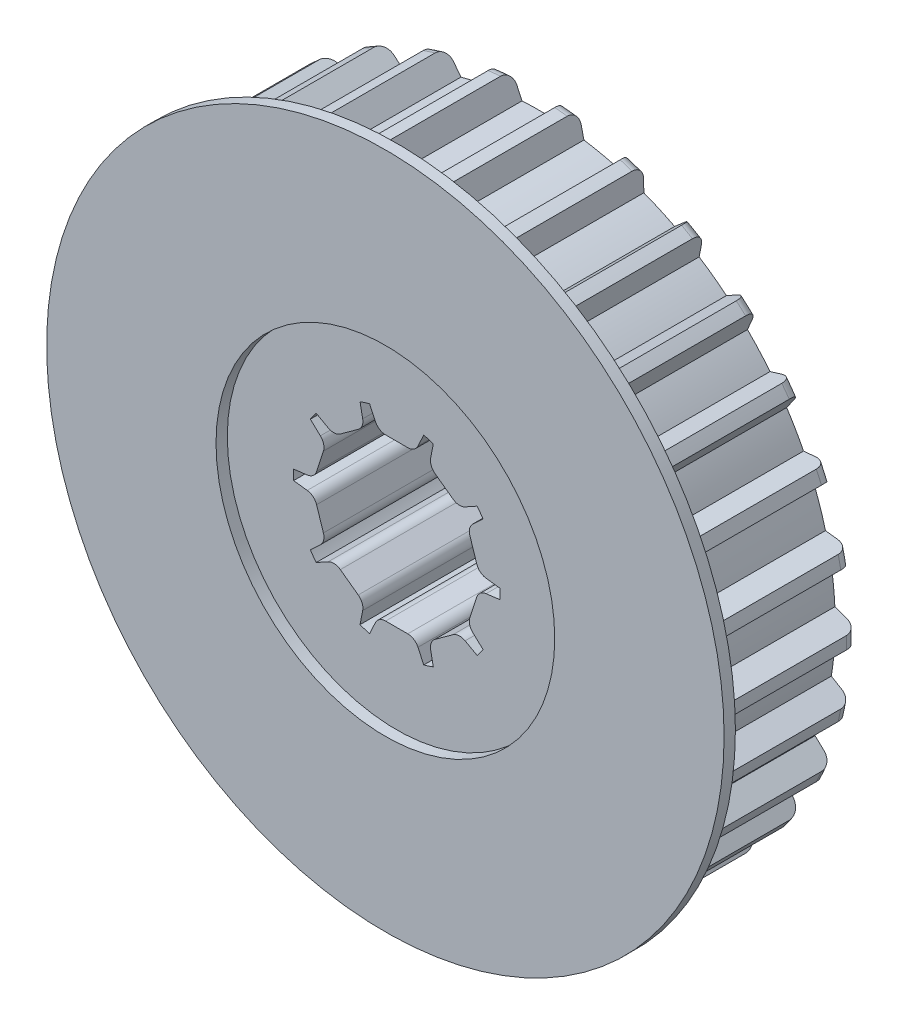
from build123d import *

# Parameters (mm, degrees)
SCHNITT_LINEAR_AUSTRAGEN1_DEPTH = 8.1
KREISMUSTER1_COUNT              = 30
AUFSATZ_LINEAR_AUSTRAGEN1_DEPTH = 7.1
VERRUNDUNG1_R                   = 0.5
KREISMUSTER2_COUNT              = 10
VERRUNDUNG1_OF_KREISMUSTER2_R   = 0.5
VERRUNDUNG2_R                   = 0.5


with BuildPart() as part:
    # Skizze1 → Rotation1 (revolve)
    with BuildSketch(Plane(origin=(0, 0, 0), x_dir=(0, 0, -1), z_dir=(1, 0, 0))):
        with BuildLine():
            Line((0, 4.57), (0, 14.12))
            Line((0, 14.12), (5.8, 14.12))
            ThreePointArc((5.8, 14.12), (6.153553391, 13.973553391), (6.3, 13.62))
            Line((6.3, 13.62), (6.3, 6.1))
            Line((6.3, 6.1), (7.1, 6.1))
            Line((7.1, 6.1), (7.1, 4.57))
            Line((7.1, 4.57), (0, 4.57))
        make_face()
    revolve(axis=Axis((0, 0, 33.276923077), (0, 0, -1)))

    # Skizze2 → Schnitt-Linear austragen1 (cut, through all)
    with BuildSketch(Plane.XY):
        with BuildLine():
            Line((0.747573546, 13.09868443), (1.2, 14.068916092))
            ThreePointArc((1.2, 14.068916092), (0, 14.12), (-1.2, 14.068916092))
            Line((-1.2, 14.068916092), (-0.747573546, 13.09868443))
            ThreePointArc((-0.747573546, 13.09868443), (0, 13.12), (0.747573546, 13.09868443))
        make_face()
    schnitt_linear_austragen1 = extrude(amount=-SCHNITT_LINEAR_AUSTRAGEN1_DEPTH, mode=Mode.SUBTRACT)

    # Kreismuster1: Schnitt-Linear austragen1 ×30 about axis
    kreismuster1_axis = Axis((0, 0, 0), (0, 0, 1))
    for i in range(1, KREISMUSTER1_COUNT):
        add(schnitt_linear_austragen1.rotate(kreismuster1_axis, i * 360 / KREISMUSTER1_COUNT), mode=Mode.SUBTRACT)

    # Skizze3 → Aufsatz-Linear austragen1 (add)
    with BuildSketch(Plane.XY):
        with BuildLine():
            Line((0.808470756, 3.57), (1.2, 4.409637173))
            ThreePointArc((1.2, 4.409637173), (0, 4.57), (-1.2, 4.409637173))
            Line((-1.2, 4.409637173), (-0.808470756, 3.57))
            Line((-0.808470756, 3.57), (0.808470756, 3.57))
        make_face()
    aufsatz_linear_austragen1 = extrude(amount=-AUFSATZ_LINEAR_AUSTRAGEN1_DEPTH)

    # Verrundung1
    verrundung1_edges = [part.edges().sort_by_distance(p)[0] for p in [
        (0.808470756, 3.57, -3.55),
        (-0.808470756, 3.57, -3.55),
    ]]
    fillet(verrundung1_edges, radius=VERRUNDUNG1_R)

    # Kreismuster2: Aufsatz-Linear austragen1 ×10 about axis
    kreismuster2_axis = Axis((0, 0, 0), (0, 0, 1))
    for i in range(1, KREISMUSTER2_COUNT):
        add(aufsatz_linear_austragen1.rotate(kreismuster2_axis, i * 360 / KREISMUSTER2_COUNT))

    # Verrundung1 of Kreismuster2
    verrundung1_of_kreismuster2_edges = [part.edges().sort_by_distance(p)[0] for p in [
        (-1.44432677, 3.363397857, -3.55),
        (-2.752459932, 2.412983483, -3.55),
        (-3.14544056, 1.872092051, -3.55),
        (-3.645102966, 0.334289289, -3.55),
        (-3.645102966, -0.334289289, -3.55),
        (-3.14544056, -1.872092051, -3.55),
        (-2.752459932, -2.412983483, -3.55),
        (-1.44432677, -3.363397857, -3.55),
        (-0.808470756, -3.57, -3.55),
        (0.808470756, -3.57, -3.55),
        (1.44432677, -3.363397857, -3.55),
        (2.752459932, -2.412983483, -3.55),
        (3.14544056, -1.872092051, -3.55),
        (3.645102966, -0.334289289, -3.55),
        (3.645102966, 0.334289289, -3.55),
        (3.14544056, 1.872092051, -3.55),
        (2.752459932, 2.412983483, -3.55),
        (1.44432677, 3.363397857, -3.55),
    ]]
    fillet(verrundung1_of_kreismuster2_edges, radius=VERRUNDUNG1_OF_KREISMUSTER2_R)

    # Skizze4 → Rotation2 (revolve)
    with BuildSketch(Plane(origin=(0, 0, 0), x_dir=(0, 0, -1), z_dir=(1, 0, 0))):
        with BuildLine():
            Line((0, 7.5), (-0.5, 7.5))
            Line((-0.5, 7.5), (-0.5, 15))
            Line((-0.5, 15), (0, 15))
            Line((0, 15), (0, 14.25))
            Line((0, 14.25), (0.653553391, 13.596446609))
            ThreePointArc((0.653553391, 13.596446609), (0.761939766, 13.434234935), (0.8, 13.242893219))
            Line((0.8, 13.242893219), (0.8, 13))
            Line((0.8, 13), (0, 13))
            Line((0, 13), (0, 7.5))
        make_face()
    revolve(axis=Axis((0, 0, 12.748207041), (0, 0, -1)))

    # Skizze5 → Schnitt-Rotation1 (revolve, cut)
    with BuildSketch(Plane(origin=(0, 0, 0), x_dir=(0, 0, -1), z_dir=(1, 0, 0))):
        Polygon((7.1, 4.2), (6.3, 5), (6.3, 6.1), (7.1, 6.1), align=None)
    revolve(axis=Axis((0, 0, -13.523679913), (0, 0, 1)), mode=Mode.SUBTRACT)

    # Verrundung2
    verrundung2_edges = [part.edges().sort_by_distance(p)[0] for p in [
        (2.46869806, 3.397871376, -7.1),
        (3.994437368, 1.297871376, -7.1),
        (3.994437368, -1.297871376, -7.1),
        (2.46869806, -3.397871376, -7.1),
        (0, -4.2, -7.1),
        (-2.46869806, -3.397871376, -7.1),
        (-3.994437368, -1.297871376, -7.1),
        (-3.994437368, 1.297871376, -7.1),
        (-2.46869806, 3.397871376, -7.1),
        (0.524669304, 4.167099965, -7.1),
    ]]
    fillet(verrundung2_edges, radius=VERRUNDUNG2_R)


solid = part.part
